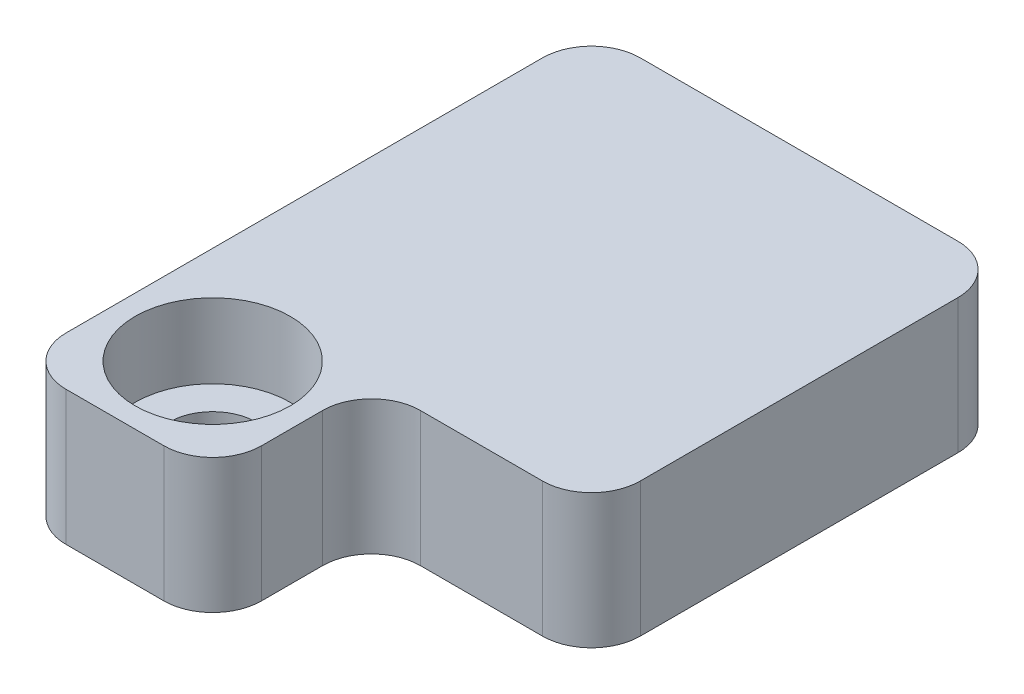
from build123d import *

# Parameters (mm, degrees)
SKETCH1_W                                      = 8.5
SKETCH1_H                                      = 8.5
EXTRUDE1_DEPTH                                 = 2.75
SKETCH8_W                                      = 7.8
SKETCH8_H                                      = 7.8
EXTRUDE6_DEPTH                                 = 0.5
SKETCH3_W                                      = 4
SKETCH3_H                                      = 2.75
EXTRUDE3_DEPTH                                 = 3.25
CBORE_FOR_0_SOCKET_HEAD_CAP_SCREW1_D           = 1.778
CBORE_FOR_0_SOCKET_HEAD_CAP_SCREW1_CBORE_D     = 3.175
CBORE_FOR_0_SOCKET_HEAD_CAP_SCREW1_CBORE_DEPTH = 1.524
FILLET1_R                                      = 1


with BuildPart() as part:
    # Sketch1 → Extrude1 (new body)
    with BuildSketch(Plane(origin=(0, 0, 0), x_dir=(1, 0, 0), z_dir=(0, 1, 0))):
        Rectangle(SKETCH1_W, SKETCH1_H)
    extrude(amount=EXTRUDE1_DEPTH)

    # Sketch8 → Extrude6 (cut)
    with BuildSketch(Plane.XZ):
        Rectangle(SKETCH8_W, SKETCH8_H)
    extrude(amount=-EXTRUDE6_DEPTH, mode=Mode.SUBTRACT)

    # Sketch3 → Extrude3 (add)
    with BuildSketch(Plane.XY.offset(4.25)):
        with Locations((-2.25, 1.375)):
            Rectangle(SKETCH3_W, SKETCH3_H)
    extrude(amount=EXTRUDE3_DEPTH)

    # CBORE for #0 Socket Head Cap Screw1 (through all)
    with Locations(Plane(origin=(-2.25, 2.75, 5.5), x_dir=(0, 0, 1), z_dir=(0, 1, 0))):
        with Locations((0, 0)):
            CounterBoreHole(CBORE_FOR_0_SOCKET_HEAD_CAP_SCREW1_D / 2, CBORE_FOR_0_SOCKET_HEAD_CAP_SCREW1_CBORE_D / 2, CBORE_FOR_0_SOCKET_HEAD_CAP_SCREW1_CBORE_DEPTH)

    # Fillet1
    fillet1_edges = [part.edges().sort_by_distance(p)[0] for p in [
        (-3.9, 0.25, 3.9),
        (-3.9, 0.25, -3.9),
        (3.9, 0.25, -3.9),
        (3.9, 0.25, 3.9),
        (-4.25, 1.375, -4.25),
        (4.25, 1.375, -4.25),
        (-0.25, 1.375, 4.25),
        (4.25, 1.375, 4.25),
        (-0.25, 1.375, 7.5),
        (-4.25, 1.375, 7.5),
    ]]
    fillet(fillet1_edges, radius=FILLET1_R)


solid = part.part
